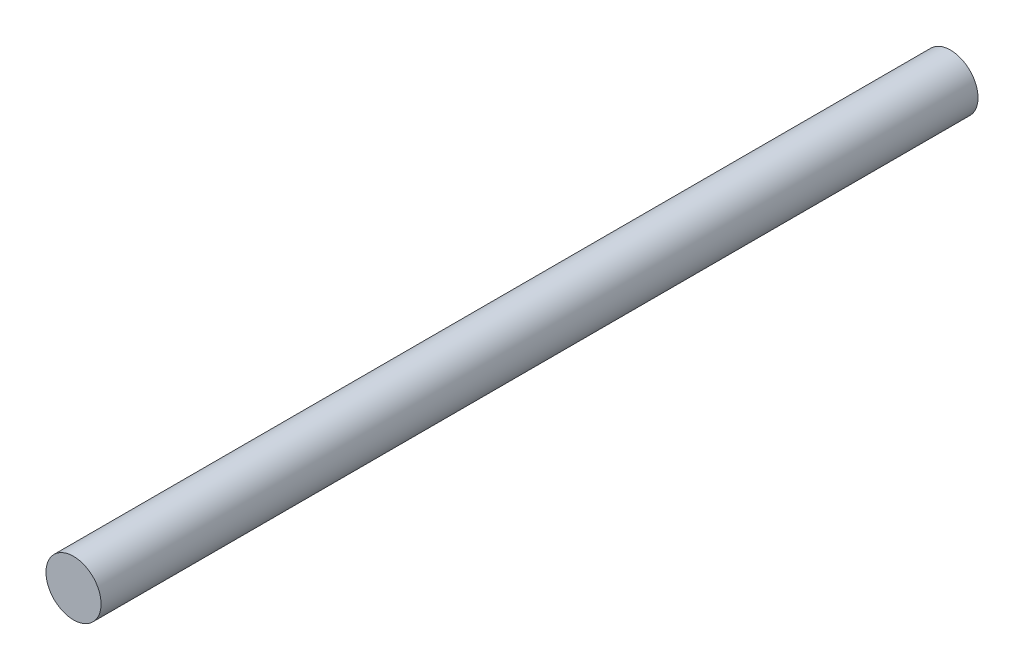
from build123d import *

# Parameters (mm, degrees)
ESQUISSE1_R        = 2.2
BOSS_EXTRU_1_DEPTH = 70


with BuildPart() as part:
    # Esquisse1 → Boss.-Extru.1 (new body)
    with BuildSketch(Plane.XY):
        with Locations((-7.781206048, 9.56078905)):
            Circle(ESQUISSE1_R)
    extrude(amount=BOSS_EXTRU_1_DEPTH)


solid = part.part
